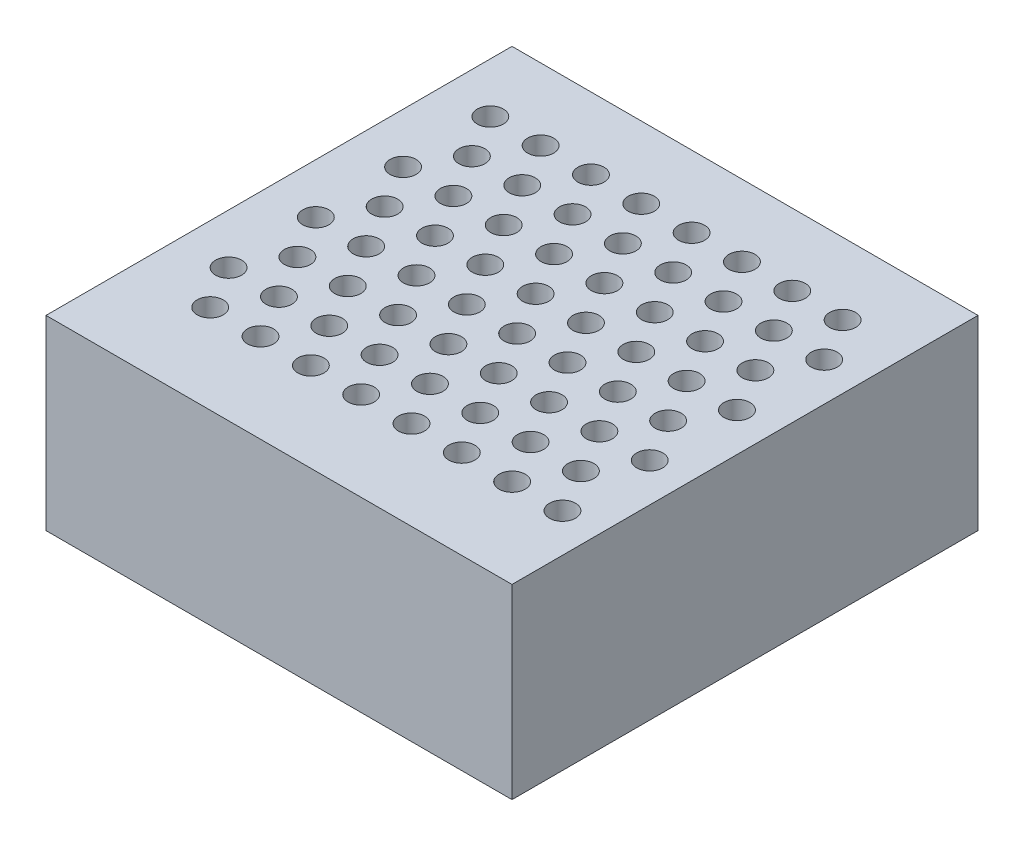
from build123d import *

# Parameters (mm, degrees)
SKETCH1_W           = 5
SKETCH1_H           = 5
BOSS_EXTRUDE1_DEPTH = 2
SKETCH2_R           = 0.14
CUT_EXTRUDE1_DEPTH  = 2


with BuildPart() as part:
    # Sketch1 → Boss-Extrude1 (new body)
    with BuildSketch(Plane(origin=(0, 0, 0), x_dir=(1, 0, 0), z_dir=(0, 1, 0))):
        with Locations((-39.316370624, 21.931364822)):
            Rectangle(SKETCH1_W, SKETCH1_H)
    extrude(amount=BOSS_EXTRUDE1_DEPTH)

    # Sketch2 → Cut-Extrude1 (cut)
    with BuildSketch(Plane(origin=(0, 0, 0), x_dir=(1, 0, 0), z_dir=(0, 1, 0))):
        with Locations((-41.280324539, 23.66257128)):
            Circle(SKETCH2_R)
        with Locations((-40.740324539, 23.66257128)):
            Circle(SKETCH2_R)
        with Locations((-40.200324539, 23.66257128)):
            Circle(SKETCH2_R)
        with Locations((-39.660324539, 23.66257128)):
            Circle(SKETCH2_R)
        with Locations((-39.120324539, 23.66257128)):
            Circle(SKETCH2_R)
        with Locations((-38.580324539, 23.66257128)):
            Circle(SKETCH2_R)
        with Locations((-38.040324539, 23.66257128)):
            Circle(SKETCH2_R)
        with Locations((-37.500324539, 23.66257128)):
            Circle(SKETCH2_R)
        with Locations((-37.500324539, 22.72657128)):
            Circle(SKETCH2_R)
        with Locations((-37.500324539, 21.79057128)):
            Circle(SKETCH2_R)
        with Locations((-41.010324539, 23.194917562)):
            Circle(SKETCH2_R)
        with Locations((-40.470324539, 23.194917562)):
            Circle(SKETCH2_R)
        with Locations((-39.930324539, 23.194917562)):
            Circle(SKETCH2_R)
        with Locations((-39.390324539, 23.194917562)):
            Circle(SKETCH2_R)
        with Locations((-38.850324539, 23.194917562)):
            Circle(SKETCH2_R)
        with Locations((-38.310324539, 23.194917562)):
            Circle(SKETCH2_R)
        with Locations((-37.500324539, 20.85457128)):
            Circle(SKETCH2_R)
        with Locations((-37.770324539, 23.194917562)):
            Circle(SKETCH2_R)
        with Locations((-37.770324539, 22.258917562)):
            Circle(SKETCH2_R)
        with Locations((-41.280324539, 22.72657128)):
            Circle(SKETCH2_R)
        with Locations((-40.740324539, 22.72657128)):
            Circle(SKETCH2_R)
        with Locations((-40.200324539, 22.72657128)):
            Circle(SKETCH2_R)
        with Locations((-39.660324539, 22.72657128)):
            Circle(SKETCH2_R)
        with Locations((-39.120324539, 22.72657128)):
            Circle(SKETCH2_R)
        with Locations((-38.580324539, 22.72657128)):
            Circle(SKETCH2_R)
        with Locations((-38.040324539, 22.72657128)):
            Circle(SKETCH2_R)
        with Locations((-37.770324539, 21.322917562)):
            Circle(SKETCH2_R)
        with Locations((-41.010324539, 20.386917562)):
            Circle(SKETCH2_R)
        with Locations((-40.470324539, 20.386917562)):
            Circle(SKETCH2_R)
        with Locations((-41.280324539, 21.79057128)):
            Circle(SKETCH2_R)
        with Locations((-40.740324539, 21.79057128)):
            Circle(SKETCH2_R)
        with Locations((-40.200324539, 21.79057128)):
            Circle(SKETCH2_R)
        with Locations((-39.660324539, 21.79057128)):
            Circle(SKETCH2_R)
        with Locations((-39.120324539, 21.79057128)):
            Circle(SKETCH2_R)
        with Locations((-38.580324539, 21.79057128)):
            Circle(SKETCH2_R)
        with Locations((-38.040324539, 21.79057128)):
            Circle(SKETCH2_R)
        with Locations((-39.930324539, 20.386917562)):
            Circle(SKETCH2_R)
        with Locations((-39.390324539, 20.386917562)):
            Circle(SKETCH2_R)
        with Locations((-38.850324539, 20.386917562)):
            Circle(SKETCH2_R)
        with Locations((-41.280324539, 20.85457128)):
            Circle(SKETCH2_R)
        with Locations((-40.740324539, 20.85457128)):
            Circle(SKETCH2_R)
        with Locations((-40.200324539, 20.85457128)):
            Circle(SKETCH2_R)
        with Locations((-39.660324539, 20.85457128)):
            Circle(SKETCH2_R)
        with Locations((-39.120324539, 20.85457128)):
            Circle(SKETCH2_R)
        with Locations((-38.580324539, 20.85457128)):
            Circle(SKETCH2_R)
        with Locations((-38.040324539, 20.85457128)):
            Circle(SKETCH2_R)
        with Locations((-38.310324539, 20.386917562)):
            Circle(SKETCH2_R)
        with Locations((-37.770324539, 20.386917562)):
            Circle(SKETCH2_R)
        with Locations((-37.230324539, 23.194917562)):
            Circle(SKETCH2_R)
        with Locations((-41.010324539, 22.258917562)):
            Circle(SKETCH2_R)
        with Locations((-40.470324539, 22.258917562)):
            Circle(SKETCH2_R)
        with Locations((-39.930324539, 22.258917562)):
            Circle(SKETCH2_R)
        with Locations((-39.390324539, 22.258917562)):
            Circle(SKETCH2_R)
        with Locations((-38.850324539, 22.258917562)):
            Circle(SKETCH2_R)
        with Locations((-38.310324539, 22.258917562)):
            Circle(SKETCH2_R)
        with Locations((-37.230324539, 22.258917562)):
            Circle(SKETCH2_R)
        with Locations((-37.230324539, 21.322917562)):
            Circle(SKETCH2_R)
        with Locations((-37.230324539, 20.386917562)):
            Circle(SKETCH2_R)
        with Locations((-41.010324539, 21.322917562)):
            Circle(SKETCH2_R)
        with Locations((-40.470324539, 21.322917562)):
            Circle(SKETCH2_R)
        with Locations((-39.930324539, 21.322917562)):
            Circle(SKETCH2_R)
        with Locations((-39.390324539, 21.322917562)):
            Circle(SKETCH2_R)
        with Locations((-38.850324539, 21.322917562)):
            Circle(SKETCH2_R)
        with Locations((-38.310324539, 21.322917562)):
            Circle(SKETCH2_R)
    extrude(amount=CUT_EXTRUDE1_DEPTH, mode=Mode.SUBTRACT)


solid = part.part
